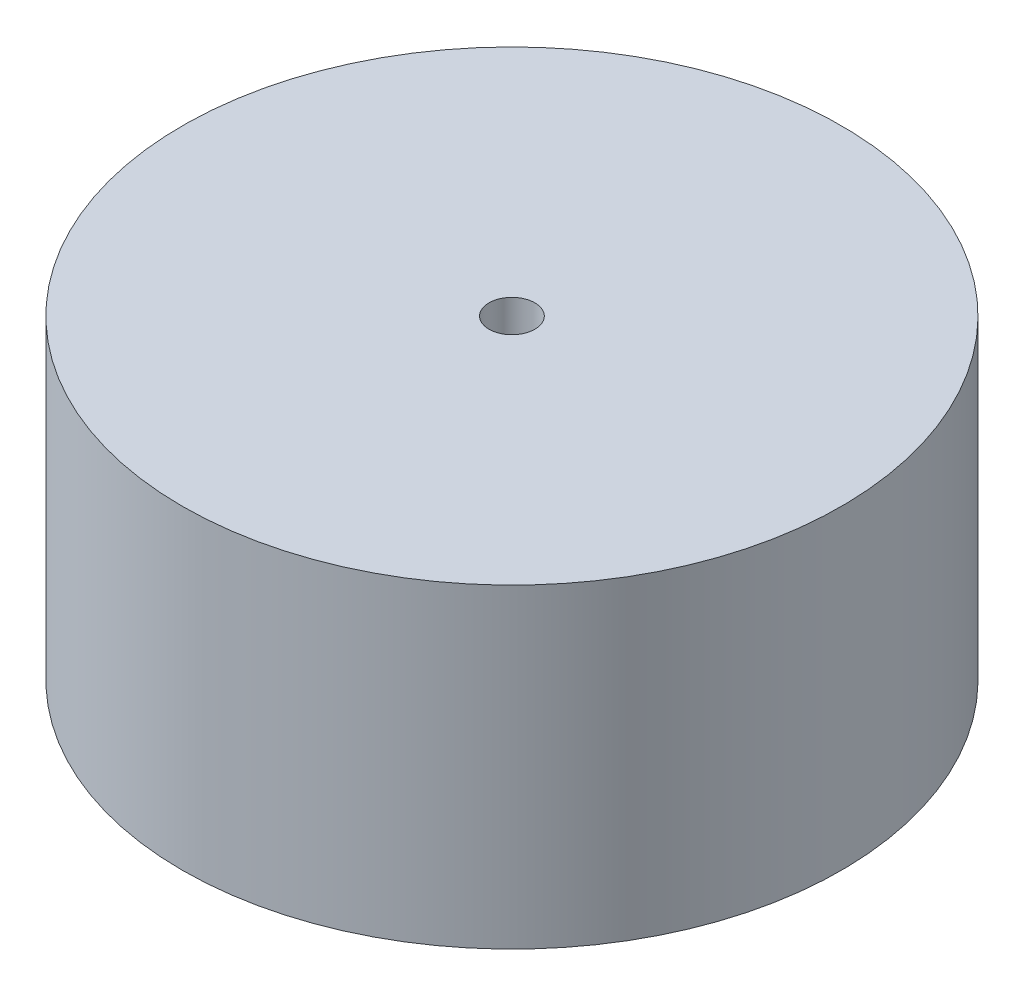
from build123d import *

# Parameters (mm, degrees)
SKETCH_1_R               = 23
EXTRUDE_1_DEPTH          = 22
SKETCH_2_R               = 1.6
CUT_EXTRUDE_1_DEPTH      = 1
CUT_EXTRUDE_1_DEPTH_BACK = 23


with BuildPart() as part:
    # 草图1 → 凸台-拉伸1 (new body)
    with BuildSketch(Plane(origin=(0, 0, 0), x_dir=(1, 0, 0), z_dir=(0, 1, 0))):
        Circle(SKETCH_1_R)
    extrude(amount=EXTRUDE_1_DEPTH)

    # 草图2 → 切除-拉伸1 (cut, two sides)
    with BuildSketch(Plane(origin=(0, 22, 0), x_dir=(1, 0, 0), z_dir=(0, 1, 0))) as cut_extrude_1_sk:
        Circle(SKETCH_2_R)
    extrude(amount=CUT_EXTRUDE_1_DEPTH, mode=Mode.SUBTRACT)
    extrude(cut_extrude_1_sk.sketch, amount=-CUT_EXTRUDE_1_DEPTH_BACK, mode=Mode.SUBTRACT)


solid = part.part
